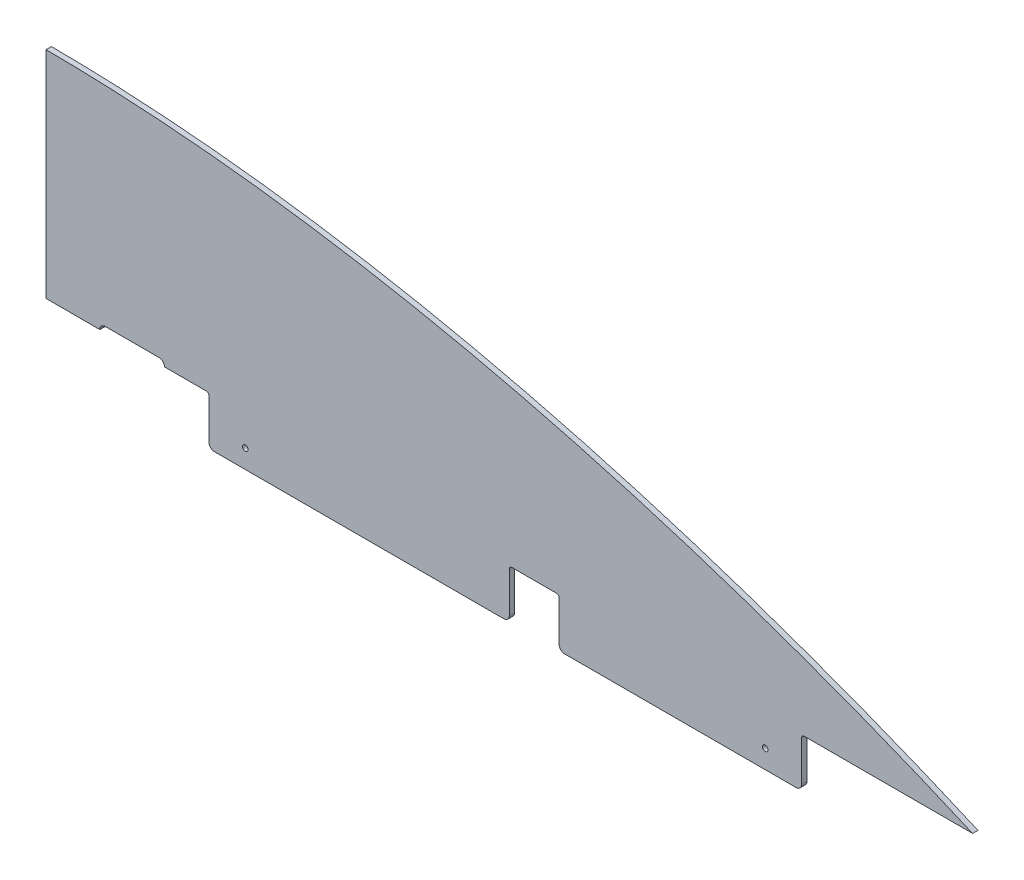
from build123d import *

# Parameters (mm, degrees)
BOSS_EXTRUDE1_DEPTH      = 6.35
CUT_EXTRUDE2_DEPTH       = 7.3500001
SKETCH8_W                = 698.5
SKETCH8_H                = 57.15
BOSS_EXTRUDE3_DEPTH      = 6.35
SKETCH12_W               = 58.7375
SKETCH12_H               = 57.15
CUT_EXTRUDE3_DEPTH       = 7.3500001
FILLET2_R                = 3.175
FILLET3_R                = 6.35
F_0_257_DIAMETER_HOLE2_D = 6.5278


with BuildPart() as part:
    # Sketch1 → Boss-Extrude1 (new body)
    with BuildSketch(Plane.XY):
        with BuildLine():
            Line((0, 254), (0, 0))
            Line((0, 0), (1092.2, 0))
            add(Edge.make_bspline(
                [(0, 254), (376.513153864, 252.276375478), (770.285770075, 140.499670678), (1092.2, 0)],
                knots=[0, 0, 0, 0, 1, 1, 1, 1], degree=3))
        make_face()
    extrude(amount=BOSS_EXTRUDE1_DEPTH)

    # Sketch7 → Cut-Extrude2 (cut, through all)
    with BuildSketch(Plane(origin=(0, 0, 0), x_dir=(-1, 0, 0), z_dir=(0, 0, -1))):
        with BuildLine():
            Line((-133.35, 0), (-63.5, 0))
            ThreePointArc((-63.5, 0), (-65.359871939, 4.490128061), (-69.85, 6.35))
            Line((-69.85, 6.35), (-133.35, 6.35))
            ThreePointArc((-133.35, 6.35), (-137.840128061, 4.490128061), (-139.7, 0))
            Line((-139.7, 0), (-133.35, 0))
        make_face()
    extrude(amount=-CUT_EXTRUDE2_DEPTH, mode=Mode.SUBTRACT)

    # Sketch8 → Boss-Extrude3 (add)
    with BuildSketch(Plane.XY.offset(6.35)):
        with Locations((541.3375, -28.575)):
            Rectangle(SKETCH8_W, SKETCH8_H)
    extrude(amount=-BOSS_EXTRUDE3_DEPTH)

    # Sketch12 → Cut-Extrude3 (cut, through all)
    with BuildSketch(Plane.XY.offset(6.35)):
        with Locations((575.46875, -28.575)):
            Rectangle(SKETCH12_W, SKETCH12_H)
    extrude(amount=-CUT_EXTRUDE3_DEPTH, mode=Mode.SUBTRACT)

    # Fillet2
    fillet2_edges = [part.edges().sort_by_distance(p)[0] for p in [
        (192.0875, 0, 3.175),
        (890.5875, 0, 3.175),
        (604.8375, 0, 3.175),
        (546.1, 0, 3.175),
    ]]
    fillet(fillet2_edges, radius=FILLET2_R)

    # Fillet3
    fillet3_edges = [part.edges().sort_by_distance(p)[0] for p in [
        (192.0875, -57.15, 3.175),
        (890.5875, -57.15, 3.175),
        (604.8375, -57.15, 3.175),
        (546.1, -57.15, 3.175),
    ]]
    fillet(fillet3_edges, radius=FILLET3_R)

    # F (0.257) Diameter Hole2 (through all)
    with Locations(Plane(origin=(0, 0, 0), x_dir=(-1, 0, 0), z_dir=(0, 0, -1))):
        with Locations((-847.725, -35.306), (-234.95, -35.306)):
            Hole(F_0_257_DIAMETER_HOLE2_D / 2)


solid = part.part
